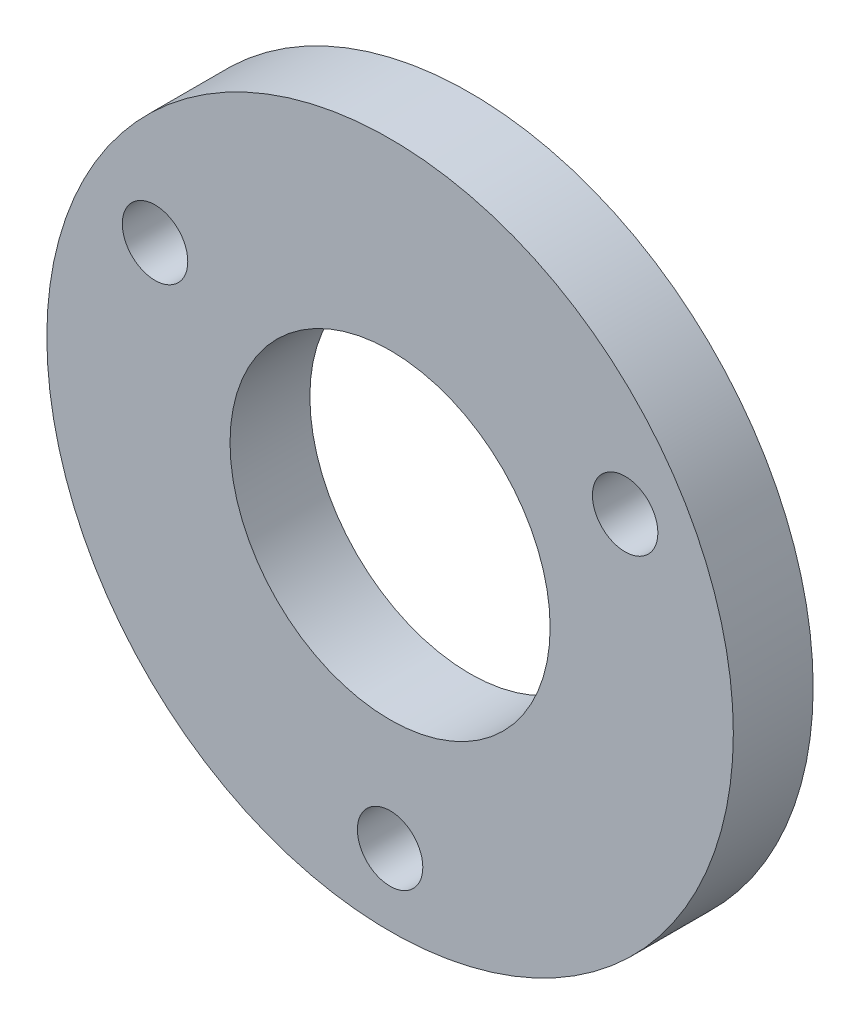
from build123d import *

# Parameters (mm, degrees)
SKETCH_1_R          = 21.5
SKETCH_1_R_2        = 18
EXTRUDE_1_DEPTH     = 5
SKETCH_2_R          = 10.025
CUT_EXTRUDE_1_DEPTH = 31.813957876
SKETCH_3_R          = 2.05
CUT_EXTRUDE_2_DEPTH = 31.813957876


with BuildPart() as part:
    # ｽｹｯﾁ1 → ﾎﾞｽ - 押し出し1 (new body)
    with BuildSketch(Plane.XY):
        Circle(SKETCH_1_R)
        Circle(SKETCH_1_R_2, mode=Mode.SUBTRACT)
        Circle(SKETCH_1_R_2)
    extrude(amount=EXTRUDE_1_DEPTH)

    # ｽｹｯﾁ2 → ｶｯﾄ - 押し出し1 (cut, through all)
    with BuildSketch(Plane.XY.offset(5)):
        Circle(SKETCH_2_R)
    extrude(amount=-CUT_EXTRUDE_1_DEPTH, mode=Mode.SUBTRACT)

    # ｽｹｯﾁ3 → ｶｯﾄ - 押し出し2 (cut, through all)
    with BuildSketch(Plane.XY.offset(5)):
        with Locations((0, -17)):
            Circle(SKETCH_3_R)
        with Locations((-14.722431864, 8.5)):
            Circle(SKETCH_3_R)
        with Locations((14.722431864, 8.5)):
            Circle(SKETCH_3_R)
    extrude(amount=-CUT_EXTRUDE_2_DEPTH, mode=Mode.SUBTRACT)


solid = part.part
